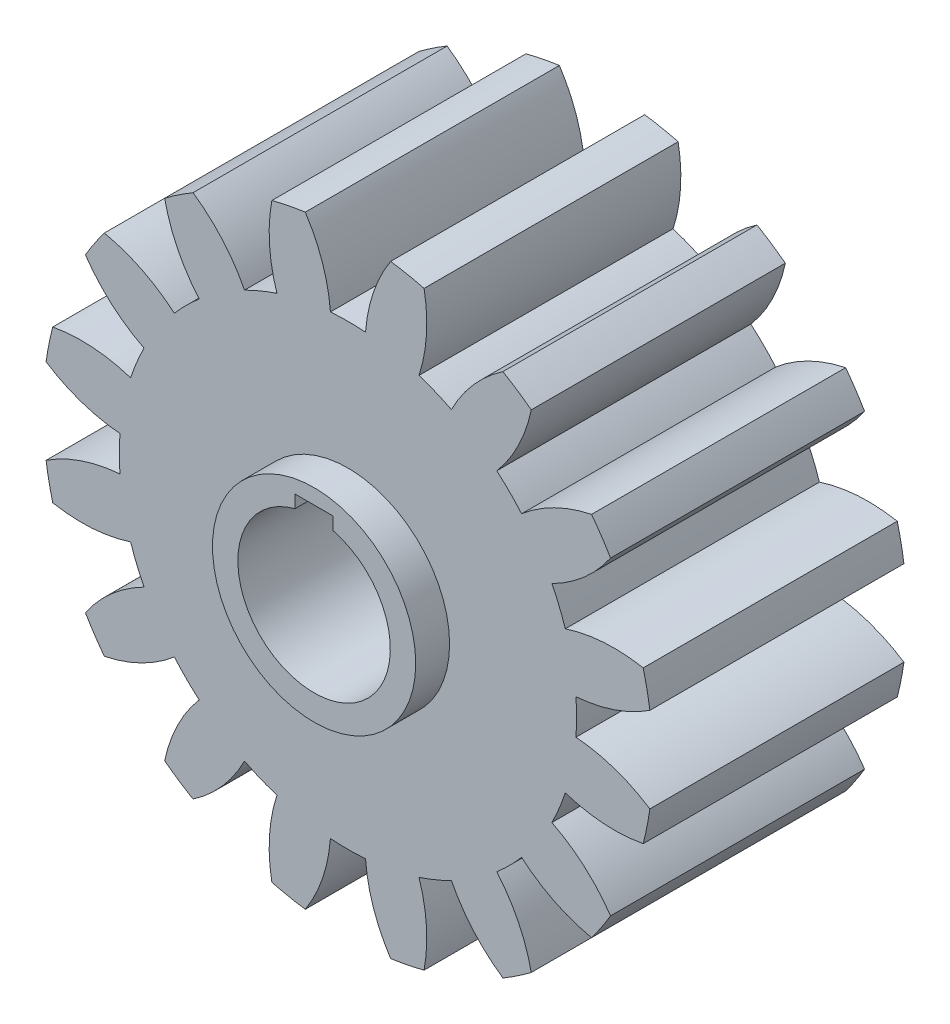
from build123d import *

# Parameters (mm, degrees)
SKETCH1_R               = 18
BOSS_EXTRUDE1_DEPTH     = 7.5
CUT_EXTRUDE1_DEPTH      = 27.537709019
SKETCH3_R               = 6
BOSS_EXTRUDE2_DEPTH     = 2
CUT_EXTRUDE2_DEPTH      = 30.546573405
CUT_EXTRUDE2_DEPTH_BACK = 30.546573405
CIRPATTERN1_COUNT       = 16


with BuildPart() as part:
    # Sketch1 → Boss-Extrude1 (new, symmetric)
    with BuildSketch(Plane.XY):
        Circle(SKETCH1_R)
    extrude(amount=BOSS_EXTRUDE1_DEPTH, both=True)

    # Sketch2 → Cut-Extrude1 (cut, symmetric)
    with BuildSketch(Plane.XY):
        with BuildLine():
            ThreePointArc((-2.51847991, 17.822941927), (-1.502149502, 15.735029188), (-1.035799814, 13.460205004))
            ThreePointArc((-1.035799814, 13.460205004), (0, 13.5), (1.035799814, 13.460205004))
            ThreePointArc((1.035799814, 13.460205004), (1.502149502, 15.735029188), (2.51847991, 17.822941927))
            ThreePointArc((2.51847991, 17.822941927), (0, 18), (-2.51847991, 17.822941927))
        make_face()
    cut_extrude1 = extrude(amount=CUT_EXTRUDE1_DEPTH, both=True, mode=Mode.SUBTRACT)

    # Sketch3 → Boss-Extrude2 (add)
    with BuildSketch(Plane.XY.offset(7.5)):
        Circle(SKETCH3_R)
        with BuildLine():
            ThreePointArc((1.125, 4.357106264), (0, -4.5), (-1.125, 4.357106264))
            Line((-1.125, 4.357106264), (-1.125, 5.107106264))
            Line((-1.125, 5.107106264), (1.125, 5.107106264))
            Line((1.125, 5.107106264), (1.125, 4.357106264))
        make_face(mode=Mode.SUBTRACT)
    extrude(amount=BOSS_EXTRUDE2_DEPTH)

    # Sketch3_3 → Cut-Extrude2 (cut, two sides: drawn at the far end of the back side and taken through both)
    with BuildSketch(Plane.XY.offset(7.5).offset(-CUT_EXTRUDE2_DEPTH_BACK)):
        with BuildLine():
            Line((-1.125, 5.107106264), (-1.125, 4.357106264))
            ThreePointArc((-1.125, 4.357106264), (0, -4.5), (1.125, 4.357106264))
            Line((1.125, 4.357106264), (1.125, 5.107106264))
            Line((1.125, 5.107106264), (-1.125, 5.107106264))
        make_face()
    extrude(amount=CUT_EXTRUDE2_DEPTH + CUT_EXTRUDE2_DEPTH_BACK, mode=Mode.SUBTRACT)

    # CirPattern1: Cut-Extrude1 ×16 about axis
    cirpattern1_axis = Axis((0, 0, 7.5), (0, 0, 1))
    for i in range(1, CIRPATTERN1_COUNT):
        add(cut_extrude1.rotate(cirpattern1_axis, i * 360 / CIRPATTERN1_COUNT), mode=Mode.SUBTRACT)


solid = part.part
